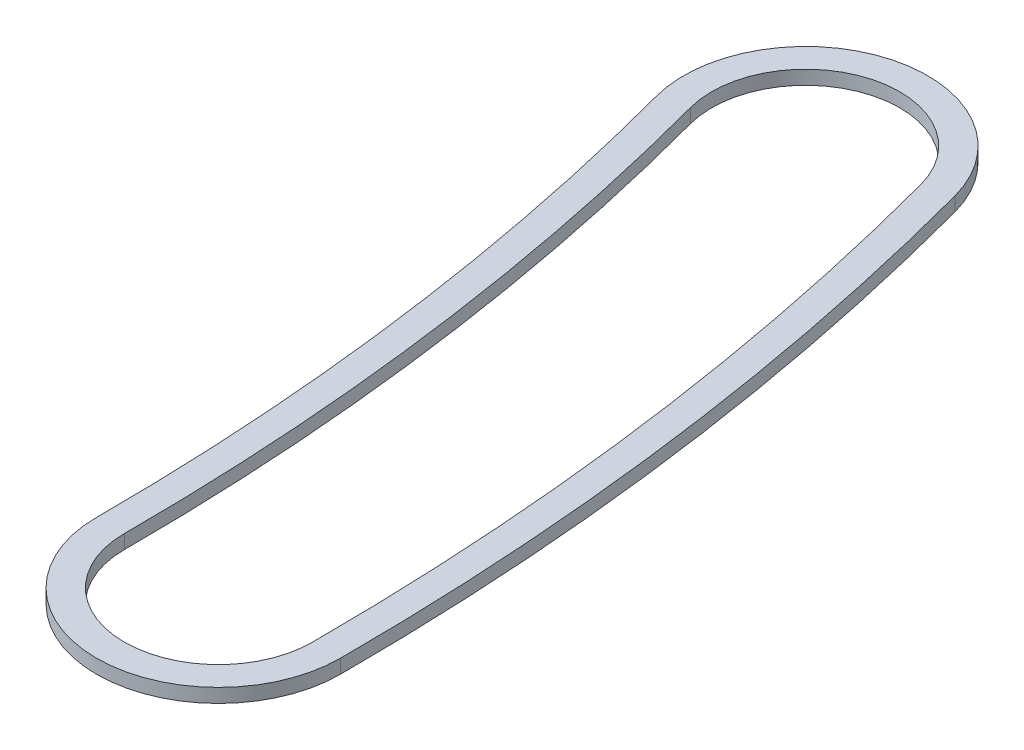
from build123d import *

# Parameters (mm, degrees)
BOSS_EXTRUDE1_DEPTH = 0.508


with BuildPart() as part:
    # Sketch1 → Boss-Extrude1 (new body)
    with BuildSketch(Plane(origin=(0, 0, 0), x_dir=(1, 0, 0), z_dir=(0, 1, 0))):
        with BuildLine():
            ThreePointArc((99.695, 0), (98.842095455, 13.012808733), (96.297975252, 25.802964701))
            ThreePointArc((96.297975252, 25.802964701), (90.853984299, 28.946054344), (87.710894656, 23.502063391))
            ThreePointArc((87.710894656, 23.502063391), (90.028150637, 11.852430885), (90.805, 0))
            ThreePointArc((90.805, 0), (95.25, -4.445), (99.695, 0))
        make_face()
        with BuildLine():
            ThreePointArc((98.679, 0), (97.834787476, 12.880194122), (95.316594612, 25.540004552))
            ThreePointArc((95.316594612, 25.540004552), (91.116944448, 27.964673704), (88.692275296, 23.76502354))
            ThreePointArc((88.692275296, 23.76502354), (91.035458616, 11.985045496), (91.821, 0))
            ThreePointArc((91.821, 0), (95.25, -3.429), (98.679, 0))
        make_face(mode=Mode.SUBTRACT)
    extrude(amount=BOSS_EXTRUDE1_DEPTH)


solid = part.part
